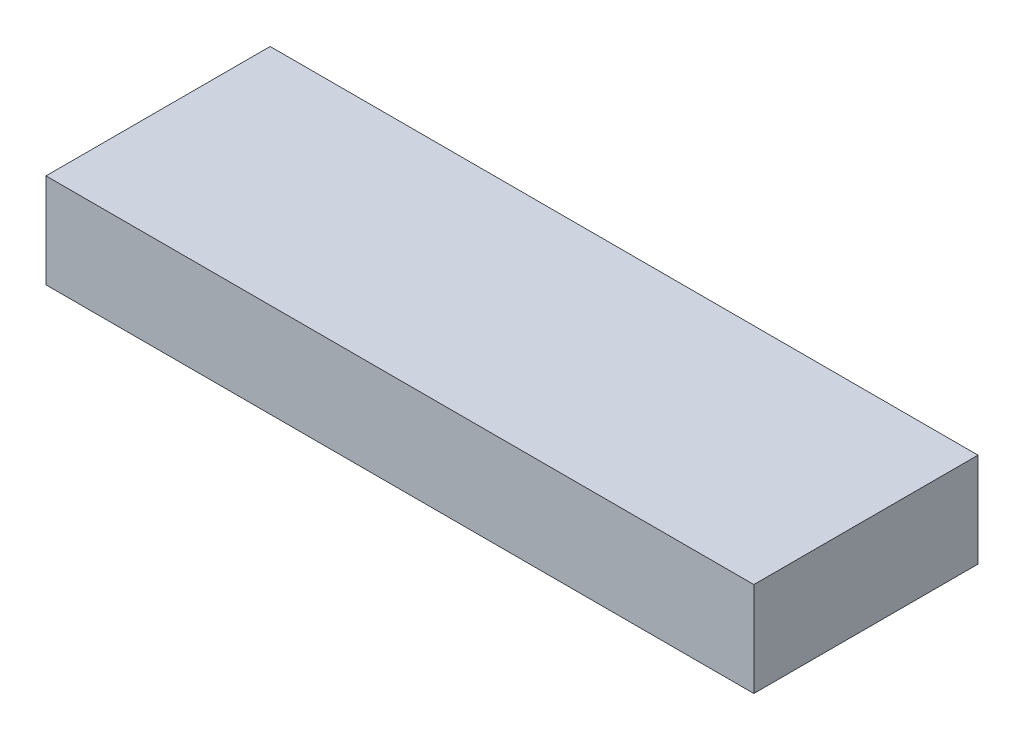
from build123d import *

# Parameters (mm, degrees)
SKETCH1_W           = 60
SKETCH1_H           = 19
BOSS_EXTRUDE1_DEPTH = 8


with BuildPart() as part:
    # Sketch1 → Boss-Extrude1 (new body)
    with BuildSketch(Plane(origin=(0, 0, 0), x_dir=(1, 0, 0), z_dir=(0, 1, 0))):
        Rectangle(SKETCH1_W, SKETCH1_H)
    extrude(amount=BOSS_EXTRUDE1_DEPTH)


solid = part.part
